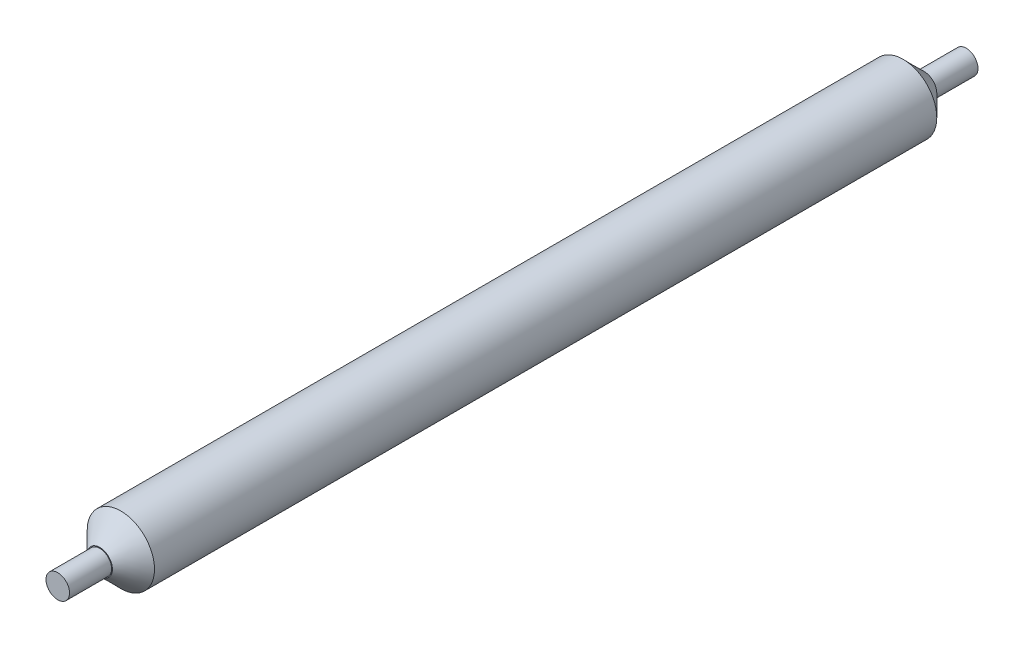
from build123d import *

# Parameters (mm, degrees)
DODANIE_WYCI_GNI_CIE1_DEPTH      = 54
DODANIE_WYCI_GNI_CIE1_DEPTH_BACK = 54
SZKIC1_R                         = 1.4
DODANIE_WYCI_GNI_CIE2_DEPTH      = 49
DODANIE_WYCI_GNI_CIE2_DEPTH_BACK = 49
SZKIC2_R                         = 4
SFAZOWANIE4_SIZE                 = 2.5


with BuildPart() as part:
    # Szkic1 → Dodanie-wyciągnięcie1 (new, two sides: drawn at the far end of the back side and taken through both)
    with BuildSketch(Plane.XY.offset(-DODANIE_WYCI_GNI_CIE1_DEPTH_BACK)):
        Circle(SZKIC1_R)
    extrude(amount=DODANIE_WYCI_GNI_CIE1_DEPTH + DODANIE_WYCI_GNI_CIE1_DEPTH_BACK)

    # Szkic2 → Dodanie-wyciągnięcie2 (add, two sides: drawn at the far end of the back side and taken through both)
    with BuildSketch(Plane.XY.offset(-DODANIE_WYCI_GNI_CIE2_DEPTH_BACK)):
        Circle(SZKIC2_R)
    extrude(amount=DODANIE_WYCI_GNI_CIE2_DEPTH + DODANIE_WYCI_GNI_CIE2_DEPTH_BACK)

    # Sfazowanie4
    sfazowanie4_edges = [part.edges().sort_by_distance(p)[0] for p in [
        (-4, 0, -49),
        (-4, 0, 49),
    ]]
    chamfer(sfazowanie4_edges, length=SFAZOWANIE4_SIZE)


solid = part.part
